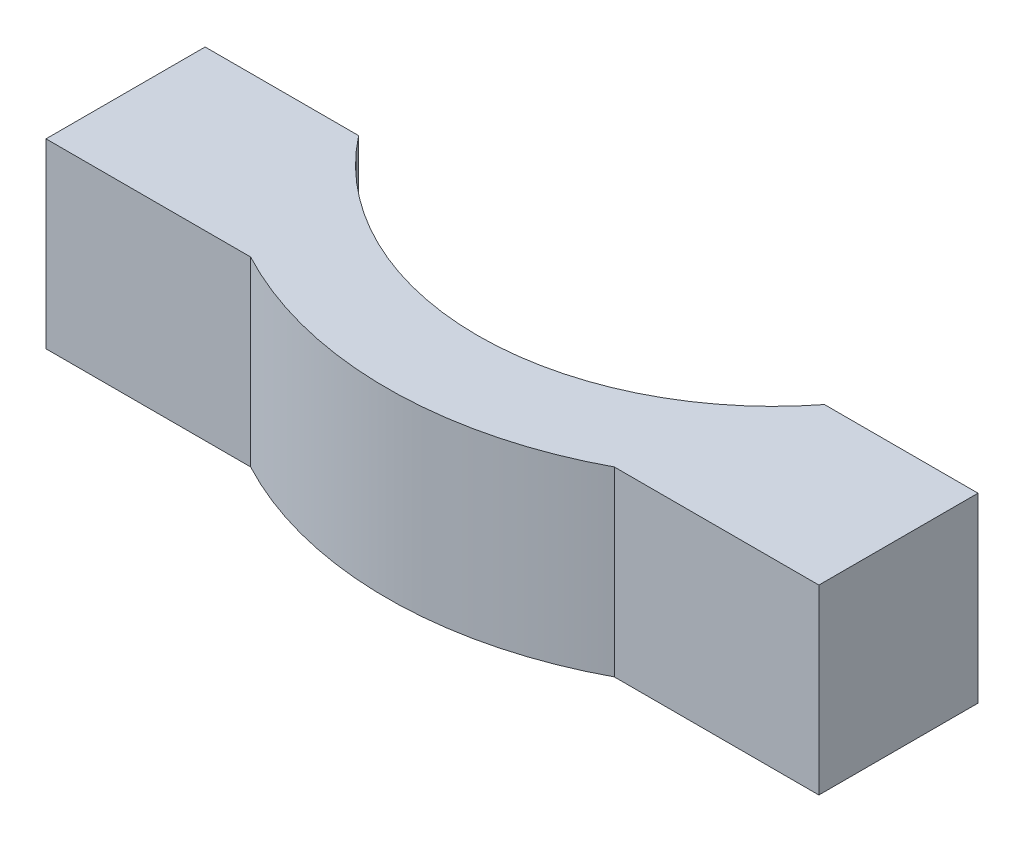
from build123d import *

# Parameters (mm, degrees)
SKETCH_3_R          = 17
EXTRUDE_2_DEPTH     = 8
SKETCH_6_W          = 34
SKETCH_6_H          = 15
EXTRUDE_3_DEPTH     = 8
SKETCH_4_R          = 13
CUT_EXTRUDE_1_DEPTH = 8
SKETCH_5_W          = 39.282271498
SKETCH_5_H          = 26.093650735
CUT_EXTRUDE_2_DEPTH = 8


with BuildPart() as part:
    # 스케치3 → 보스-돌출2 (new body)
    with BuildSketch(Plane(origin=(0, 0, 0), x_dir=(1, 0, 0), z_dir=(0, 1, 0))):
        Circle(SKETCH_3_R)
    extrude(amount=EXTRUDE_2_DEPTH)

    # 스케치6 → 보스-돌출3 (add)
    with BuildSketch(Plane(origin=(0, 8, 0), x_dir=(1, 0, 0), z_dir=(0, 1, 0))):
        with Locations((0, -7.5)):
            Rectangle(SKETCH_6_W, SKETCH_6_H)
    extrude(amount=-EXTRUDE_3_DEPTH)

    # 스케치4 → 컷-돌출1 (cut)
    with BuildSketch(Plane(origin=(0, 8, 0), x_dir=(1, 0, 0), z_dir=(0, 1, 0))):
        Circle(SKETCH_4_R)
    extrude(amount=-CUT_EXTRUDE_1_DEPTH, mode=Mode.SUBTRACT)

    # 스케치5 → 컷-돌출2 (cut)
    with BuildSketch(Plane(origin=(0, 8, 0), x_dir=(1, 0, 0), z_dir=(0, 1, 0))):
        with Locations((-0.462251139, 5.046825368)):
            Rectangle(SKETCH_5_W, SKETCH_5_H)
    extrude(amount=-CUT_EXTRUDE_2_DEPTH, mode=Mode.SUBTRACT)


solid = part.part
